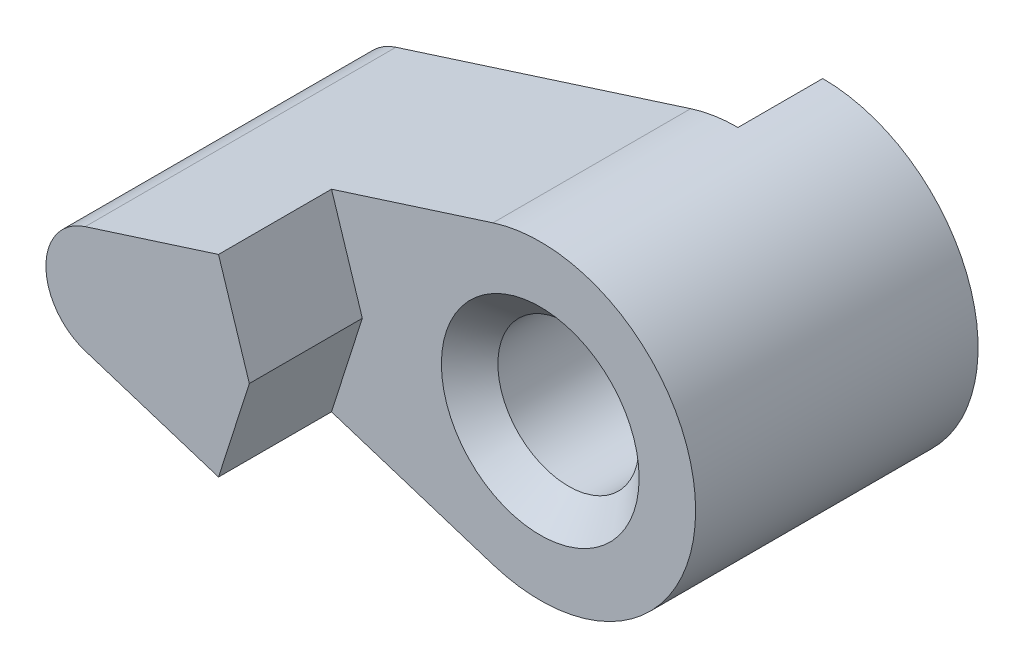
from build123d import *

# Parameters (mm, degrees)
ESQUISSE1_R             = 2.5
EXTRUSION1_DEPTH        = 14
ENL_V_MAT_EXTRU_1_DEPTH = 4
ESQUISSE4_R             = 2.5
ENL_V_MAT_EXTRU_2_DEPTH = 3
CHANFREIN1_SIZE         = 1


with BuildPart() as part:
    # Esquisse1 → Extrusion1 (new body)
    with BuildSketch(Plane.XY):
        with BuildLine():
            Line((-1.673913043, 5.239085333), (-12.108695652, 1.905121939))
            ThreePointArc((-12.108695652, 1.905121939), (-13.5, 0), (-12.108695652, -1.905121939))
            Line((-12.108695652, -1.905121939), (-1.673913043, -5.239085333))
            ThreePointArc((-1.673913043, -5.239085333), (5.5, 0), (-1.673913043, 5.239085333))
        make_face()
        Circle(ESQUISSE1_R, mode=Mode.SUBTRACT)
    extrude(amount=EXTRUSION1_DEPTH)

    # Esquisse2 → Enlèv. mat.-Extru.1 (cut)
    with BuildSketch(Plane.XY.offset(14)):
        with BuildLine():
            Line((-1.673913043, 5.239085333), (-7.389278861, 3.412998376))
            Line((-7.389278861, 3.412998376), (-6.298809411, 0))
            Line((-6.298809411, 0), (-7.389278861, -3.412998376))
            Line((-7.389278861, -3.412998376), (-1.673913043, -5.239085333))
            ThreePointArc((-1.673913043, -5.239085333), (5.5, 0), (-1.673913043, 5.239085333))
        make_face()
    extrude(amount=-ENL_V_MAT_EXTRU_1_DEPTH, mode=Mode.SUBTRACT)

    # Esquisse4 → Enlèv. mat.-Extru.2 (cut)
    with BuildSketch(Plane(origin=(0, 0, 0), x_dir=(-1, 0, 0), z_dir=(0, 0, -1))):
        Circle(ESQUISSE4_R)
        with BuildLine():
            Line((1.673913043, -5.239085333), (12.108695652, -1.905121939))
            ThreePointArc((12.108695652, -1.905121939), (13.5, 0), (12.108695652, 1.905121939))
            Line((12.108695652, 1.905121939), (1.673913043, 5.239085333))
            ThreePointArc((1.673913043, 5.239085333), (0.847062769, 5.434379879), (0, 5.5))
            Line((0, 5.5), (-1.881110788, -5.168309414))
            ThreePointArc((-1.881110788, -5.168309414), (-0.10947618, -5.498910344), (1.673913043, -5.239085333))
        make_face()
    extrude(amount=-ENL_V_MAT_EXTRU_2_DEPTH, mode=Mode.SUBTRACT)

    # Chanfrein1
    chanfrein1_edges = [part.edges().sort_by_distance(p)[0] for p in [
        (-2.5, 0, 10),
    ]]
    chamfer(chanfrein1_edges, length=CHANFREIN1_SIZE)


solid = part.part
